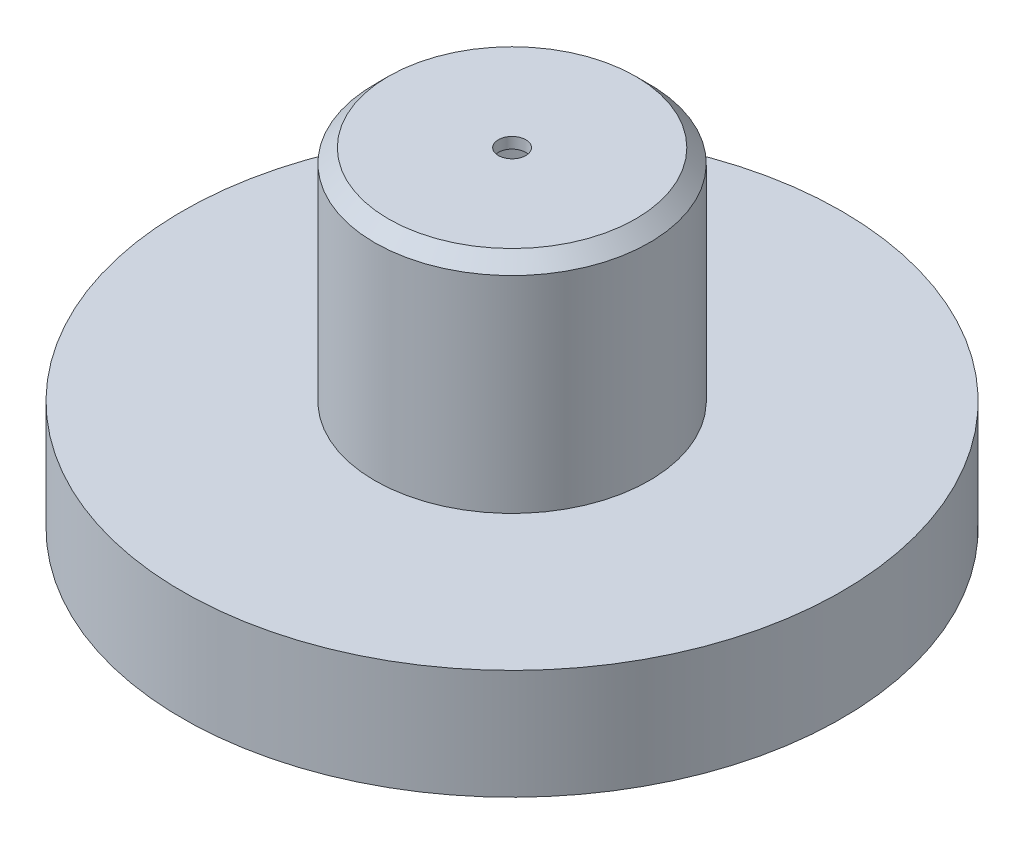
from build123d import *

# Parameters (mm, degrees)
BOSS_EXTRUDE1_DEPTH = 100
SKETCH3_R           = 50
BOSS_EXTRUDE3_DEPTH = 80
CHAMFER1_SIZE       = 5
FILLET1_R           = 1
SKETCH4_R           = 5
CUT_EXTRUDE1_DEPTH  = 20
SKETCH5_R           = 15
SKETCH5_R_2         = 2.5
SKETCH5_W           = 60
SKETCH5_H           = 10
SKETCH5_W_2         = 50
CUT_EXTRUDE2_DEPTH  = 20
SKETCH6_W           = 150
SKETCH6_H           = 200
CUT_EXTRUDE3_DEPTH  = 181
SKETCH7_R           = 120
BOSS_EXTRUDE4_DEPTH = 40
SHELL1_T            = -4
SKETCH10_R          = 5
CUT_EXTRUDE4_DEPTH  = 209


with BuildPart() as part:
    # Sketch2 → Boss-Extrude1 (new, symmetric)
    with BuildSketch(Plane.XY):
        with BuildLine():
            Line((-75, 50), (-70, 50))
            ThreePointArc((-70, 50), (-65, 45), (-60, 50))
            Line((-60, 50), (-35, 50))
            Line((-35, 50), (-25, 50))
            Line((-25, 50), (25, 50))
            Line((25, 50), (35, 50))
            Line((35, 50), (60, 50))
            ThreePointArc((60, 50), (65, 45), (70, 50))
            Line((70, 50), (75, 50))
            Line((75, 50), (75, 15))
            ThreePointArc((75, 15), (70.980762114, 0), (75, -15))
            Line((75, -15), (75, -50))
            Line((75, -50), (70, -50))
            ThreePointArc((70, -50), (65, -45), (60, -50))
            Line((60, -50), (35, -50))
            ThreePointArc((35, -50), (30, -45), (25, -50))
            Line((25, -50), (-25, -50))
            ThreePointArc((-25, -50), (-30, -45), (-35, -50))
            Line((-35, -50), (-60, -50))
            ThreePointArc((-60, -50), (-65, -45), (-70, -50))
            Line((-70, -50), (-75, -50))
            Line((-75, -50), (-75, -15))
            ThreePointArc((-75, -15), (-70.980762114, 0), (-75, 15))
            Line((-75, 15), (-75, 50))
        make_face()
    extrude(amount=BOSS_EXTRUDE1_DEPTH, both=True)

    # Sketch3 → Boss-Extrude3 (add)
    with BuildSketch(Plane(origin=(0, 50, 0), x_dir=(1, 0, 0), z_dir=(0, 1, 0))):
        with Locations(Location((0, 0, 0), (0, 0, 90))):
            Circle(SKETCH3_R)
    extrude(amount=BOSS_EXTRUDE3_DEPTH)

    # Chamfer1
    chamfer1_edges = [part.edges().sort_by_distance(p)[0] for p in [
        (0, 130, 50),
    ]]
    chamfer(chamfer1_edges, length=CHAMFER1_SIZE)

    # Fillet1
    fillet1_edges = [part.edges().sort_by_distance(p)[0] for p in [
        (-75, -50, 0),
        (-75, 50, 0),
        (75, 50, 0),
        (75, -50, 0),
    ]]
    fillet(fillet1_edges, radius=FILLET1_R)

    # Sketch4 → Cut-Extrude1 (cut)
    with BuildSketch(Plane.XZ.offset(50)):
        with Locations(Location((-47.5, 80, 0), (0, 0, 270))):
            Circle(SKETCH4_R)
        with Locations(Location((47.5, 80, 0), (0, 0, 270))):
            Circle(SKETCH4_R)
        with Locations(Location((47.5, 40, 0), (0, 0, 270))):
            Circle(SKETCH4_R)
        with Locations(Location((47.5, 0, 0), (0, 0, 270))):
            Circle(SKETCH4_R)
        with Locations(Location((47.5, -40, 0), (0, 0, 270))):
            Circle(SKETCH4_R)
        with Locations(Location((47.5, -80, 0), (0, 0, 270))):
            Circle(SKETCH4_R)
        with Locations(Location((-47.5, 40, 0), (0, 0, 270))):
            Circle(SKETCH4_R)
        with Locations(Location((-47.5, 0, 0), (0, 0, 270))):
            Circle(SKETCH4_R)
        with Locations(Location((-47.5, -40, 0), (0, 0, 270))):
            Circle(SKETCH4_R)
        with Locations(Location((-47.5, -80, 0), (0, 0, 270))):
            Circle(SKETCH4_R)
    extrude(amount=-CUT_EXTRUDE1_DEPTH, mode=Mode.SUBTRACT)

    # Sketch5 → Cut-Extrude2 (cut)
    with BuildSketch(Plane(origin=(0, 0, -100), x_dir=(-1, 0, 0), z_dir=(0, 0, -1))):
        with Locations((40, 25)):
            Circle(SKETCH5_R)
        with Locations((35, 25)):
            Circle(SKETCH5_R_2, mode=Mode.SUBTRACT)
        with Locations((45, 25)):
            Circle(SKETCH5_R_2, mode=Mode.SUBTRACT)
        with Locations((-25, -20)):
            Rectangle(SKETCH5_W, SKETCH5_H)
        with Locations((-25, 10)):
            Rectangle(SKETCH5_W_2, SKETCH5_H)
    extrude(amount=-CUT_EXTRUDE2_DEPTH, mode=Mode.SUBTRACT)

    # Sketch6 → Cut-Extrude3 (cut)
    with BuildSketch(Plane(origin=(0, 50, 0), x_dir=(1, 0, 0), z_dir=(0, 1, 0))):
        Rectangle(SKETCH6_W, SKETCH6_H)
    extrude(amount=-CUT_EXTRUDE3_DEPTH, mode=Mode.SUBTRACT)

    # Sketch7 → Boss-Extrude4 (add)
    with BuildSketch(Plane.XZ.offset(-50)):
        with Locations(Location((0, 0, 0), (0, 0, 270))):
            Circle(SKETCH7_R)
    extrude(amount=BOSS_EXTRUDE4_DEPTH)

    # Shell1
    shell1_openings = [part.faces().sort_by_distance(p)[0] for p in [
        (0, 10, 0),
    ]]
    offset(amount=SHELL1_T, openings=shell1_openings, kind=Kind.INTERSECTION)

    # Sketch10 → Cut-Extrude4 (cut)
    with BuildSketch(Plane(origin=(0, 130, 0), x_dir=(1, 0, 0), z_dir=(0, 1, 0))):
        with Locations(Location((0, 0, 0), (0, 0, 270))):
            Circle(SKETCH10_R)
    extrude(amount=-CUT_EXTRUDE4_DEPTH, mode=Mode.SUBTRACT)


solid = part.part
